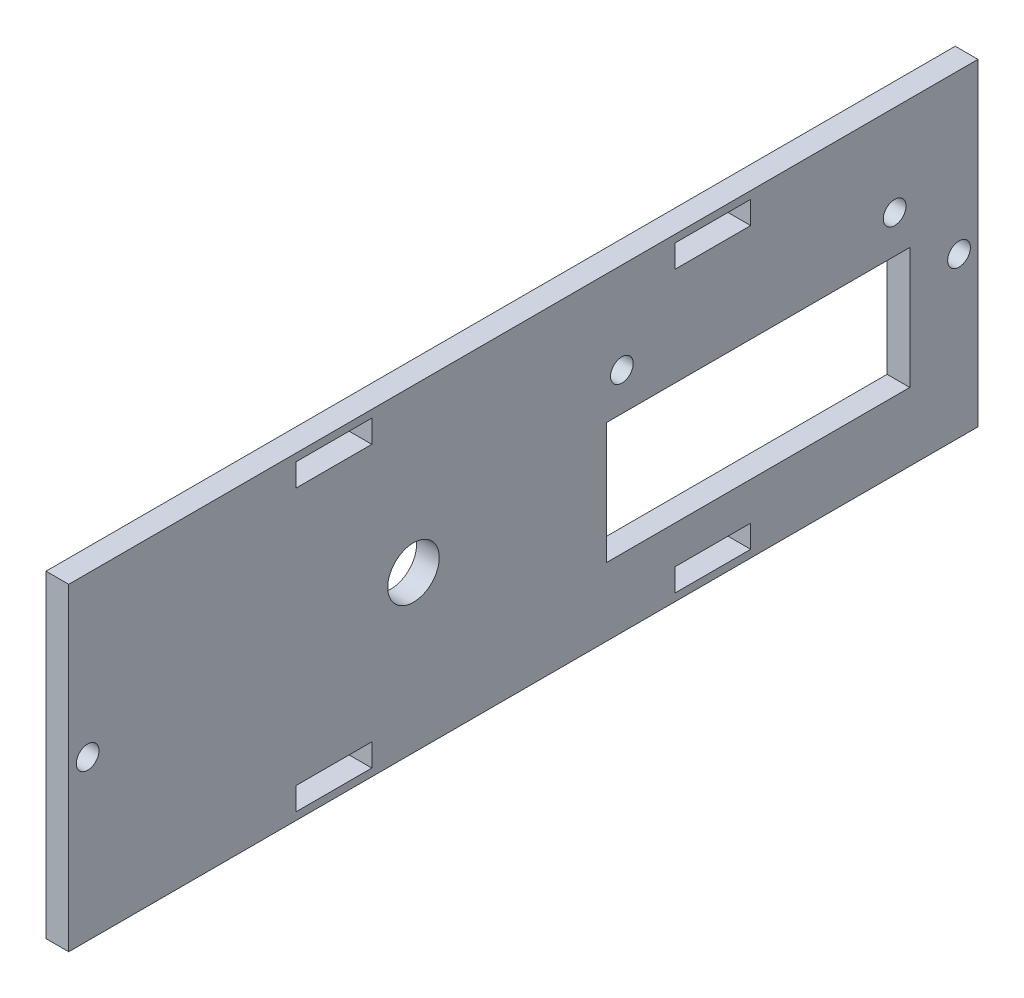
from build123d import *

# Parameters (mm, degrees)
SKETCH1_W           = 120
SKETCH1_H           = 42
SKETCH1_R           = 1.5
SKETCH1_R_2         = 3.4
SKETCH1_W_2         = 10
SKETCH1_H_2         = 3
SKETCH1_W_3         = 40
SKETCH1_H_3         = 16
BOSS_EXTRUDE1_DEPTH = 3


with BuildPart() as part:
    # Sketch1 → Boss-Extrude1 (new body)
    with BuildSketch(Plane(origin=(0, 0, 0), x_dir=(0, 0, -1), z_dir=(1, 0, 0))):
        Rectangle(SKETCH1_W, SKETCH1_H)
        with Locations((49, 9)):
            Circle(SKETCH1_R, mode=Mode.SUBTRACT)
        with Locations((13, 9)):
            Circle(SKETCH1_R, mode=Mode.SUBTRACT)
        with Locations((-14.5, -0.4)):
            Circle(SKETCH1_R_2, mode=Mode.SUBTRACT)
        with Locations((57.5, 0)):
            Circle(SKETCH1_R, mode=Mode.SUBTRACT)
        with Locations((-57.5, 0)):
            Circle(SKETCH1_R, mode=Mode.SUBTRACT)
        with Locations((25, -18.5)):
            Rectangle(SKETCH1_W_2, SKETCH1_H_2, mode=Mode.SUBTRACT)
        with Locations((-25, -18.5)):
            Rectangle(SKETCH1_W_2, SKETCH1_H_2, mode=Mode.SUBTRACT)
        with Locations((25, 18.5)):
            Rectangle(SKETCH1_W_2, SKETCH1_H_2, mode=Mode.SUBTRACT)
        with Locations((-25, 18.5)):
            Rectangle(SKETCH1_W_2, SKETCH1_H_2, mode=Mode.SUBTRACT)
        with Locations((31, -4)):
            Rectangle(SKETCH1_W_3, SKETCH1_H_3, mode=Mode.SUBTRACT)
    extrude(amount=BOSS_EXTRUDE1_DEPTH)


solid = part.part
